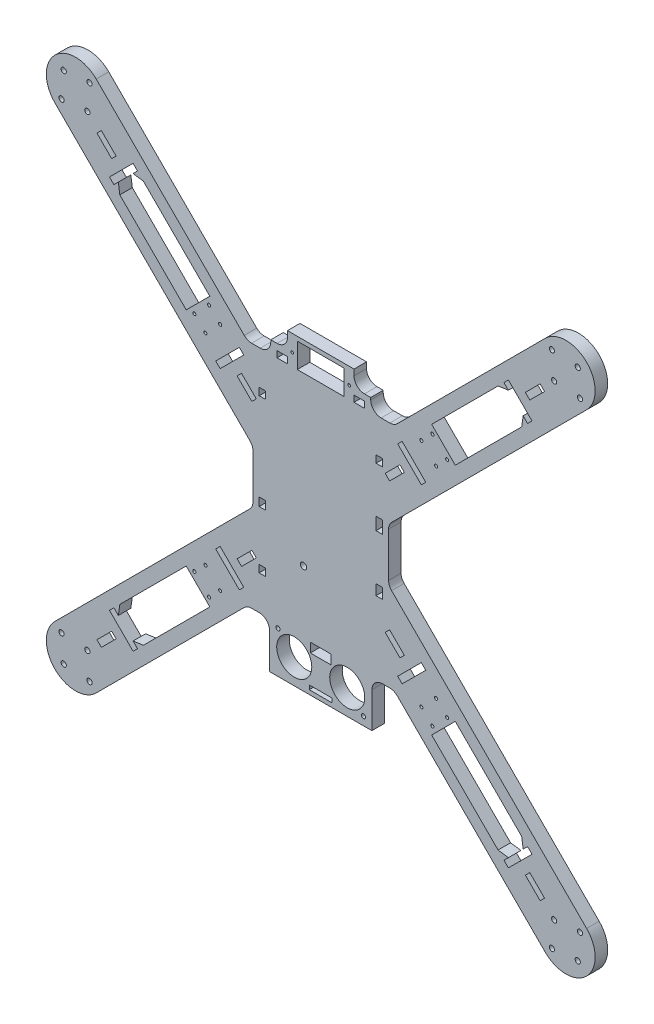
from build123d import *

# Parameters (mm, degrees)
BOSS_EXTRUDE1_DEPTH = 6
SKETCH4_R           = 1.25
CUT_EXTRUDE1_DEPTH  = 7
SKETCH5_R           = 0.65
SKETCH5_W           = 22.5
SKETCH5_H           = 11.8
CUT_EXTRUDE2_DEPTH  = 7
SKETCH6_R           = 1.5
CUT_EXTRUDE3_DEPTH  = 7
SKETCH7_R           = 1
SKETCH7_R_2         = 8.4
SKETCH7_W           = 10
SKETCH7_H           = 4.5
SKETCH7_W_2         = 11
SKETCH7_H_2         = 2
CUT_EXTRUDE4_DEPTH  = 7
CUT_EXTRUDE5_DEPTH  = 7
BOSS_EXTRUDE2_REACH = 195.969
SKETCH9_W           = 6
SKETCH9_H           = 20
BOSS_EXTRUDE3_REACH = 195.969
SKETCH11_W          = 6
SKETCH11_H          = 20
BOSS_EXTRUDE4_REACH = 195.969
SKETCH12_W          = 6
SKETCH12_H          = 20
BOSS_EXTRUDE5_REACH = 195.969
SKETCH13_W          = 6
SKETCH13_H          = 20
SKETCH14_W          = 3
SKETCH14_H          = 6
SKETCH14_H_2        = 3.5
SKETCH14_H_3        = 4
SKETCH14_H_4        = 5
CUT_EXTRUDE6_DEPTH  = 7
SKETCH15_R          = 0.75
CUT_EXTRUDE7_DEPTH  = 7
SKETCH17_W          = 8
SKETCH17_H          = 6
BOSS_EXTRUDE8_DEPTH = 6
SKETCH19_W          = 5
SKETCH19_H          = 3
CUT_EXTRUDE9_DEPTH  = 7
FILLET1_R           = 5


with BuildPart() as part:
    # Sketch1 → Boss-Extrude1 (new body)
    with BuildSketch(Plane.XY):
        with BuildLine():
            Line((35.201010127, 55), (15.95, 55))
            Line((15.95, 55), (15.95, 68.8))
            Line((15.95, 68.8), (-15.95, 68.8))
            Line((-15.95, 68.8), (-15.95, 55))
            Line((-15.95, 55), (-35.201010127, 55))
            Line((-35.201010127, 55), (-107.600505063, 127.399494937))
            ThreePointArc((-107.600505063, 127.399494937), (-127.399494937, 127.399494937), (-127.399494937, 107.600505063))
            Line((-127.399494937, 107.600505063), (-32.5, 12.701010127))
            Line((-32.5, 12.701010127), (-32.5, -12.701010127))
            Line((-32.5, -12.701010127), (-127.399494937, -107.600505063))
            ThreePointArc((-127.399494937, -107.600505063), (-127.399494937, -127.399494937), (-107.600505063, -127.399494937))
            Line((-107.600505063, -127.399494937), (-35.201010127, -55))
            Line((-35.201010127, -55), (-24.5, -55))
            Line((-24.5, -55), (-24.5, -77))
            Line((-24.5, -77), (24.5, -77))
            Line((24.5, -77), (24.5, -55))
            Line((24.5, -55), (35.201010127, -55))
            Line((35.201010127, -55), (107.600505063, -127.399494937))
            ThreePointArc((107.600505063, -127.399494937), (127.399494937, -127.399494937), (127.399494937, -107.600505063))
            Line((127.399494937, -107.600505063), (32.5, -12.701010127))
            Line((32.5, -12.701010127), (32.5, 12.701010127))
            Line((32.5, 12.701010127), (127.399494937, 107.600505063))
            ThreePointArc((127.399494937, 107.600505063), (127.399494937, 127.399494937), (107.600505063, 127.399494937))
            Line((107.600505063, 127.399494937), (35.201010127, 55))
        make_face()
    extrude(amount=-BOSS_EXTRUDE1_DEPTH)

    # Sketch4 → Cut-Extrude1 (cut, through all)
    with BuildSketch(Plane.XY):
        with Locations((-110.782485579, 124.217514421)):
            Circle(SKETCH4_R)
        with Locations((-124.217514421, 110.782485579)):
            Circle(SKETCH4_R)
        with Locations((-123.156854249, 123.156854249)):
            Circle(SKETCH4_R)
        with Locations((-111.843145751, 111.843145751)):
            Circle(SKETCH4_R)
        with Locations((111.843145751, 111.843145751)):
            Circle(SKETCH4_R)
        with Locations((110.782485579, 124.217514421)):
            Circle(SKETCH4_R)
        with Locations((123.156854249, 123.15685425)):
            Circle(SKETCH4_R)
        with Locations((124.217514421, 110.782485579)):
            Circle(SKETCH4_R)
        with Locations((111.843145751, -111.84314575)):
            Circle(SKETCH4_R)
        with Locations((124.217514421, -110.782485579)):
            Circle(SKETCH4_R)
        with Locations((123.15685425, -123.156854249)):
            Circle(SKETCH4_R)
        with Locations((110.782485579, -124.217514421)):
            Circle(SKETCH4_R)
        with Locations((-111.84314575, -111.843145751)):
            Circle(SKETCH4_R)
        with Locations((-110.782485579, -124.217514421)):
            Circle(SKETCH4_R)
        with Locations((-123.156854249, -123.156854249)):
            Circle(SKETCH4_R)
        with Locations((-124.217514421, -110.782485579)):
            Circle(SKETCH4_R)
    extrude(amount=-CUT_EXTRUDE1_DEPTH, mode=Mode.SUBTRACT)

    # Sketch5 → Cut-Extrude2 (cut, through all)
    with BuildSketch(Plane.XY):
        with Locations((-13.65, 60.9)):
            Circle(SKETCH5_R)
        with Locations((13.65, 60.9)):
            Circle(SKETCH5_R)
        with Locations((0, 60.9)):
            Rectangle(SKETCH5_W, SKETCH5_H)
    extrude(amount=-CUT_EXTRUDE2_DEPTH, mode=Mode.SUBTRACT)

    # Sketch6 → Cut-Extrude3 (cut, through all)
    with BuildSketch(Plane.XY):
        with Locations((-8.25, -25)):
            Circle(SKETCH6_R)
    extrude(amount=-CUT_EXTRUDE3_DEPTH, mode=Mode.SUBTRACT)

    # Sketch7 → Cut-Extrude4 (cut, through all)
    with BuildSketch(Plane.XY):
        with Locations((-20.5, -57)):
            Circle(SKETCH7_R)
        with Locations((-12.7, -65)):
            Circle(SKETCH7_R_2)
        with Locations((12.7, -65)):
            Circle(SKETCH7_R_2)
        with Locations((20.5, -73)):
            Circle(SKETCH7_R)
        with Locations((0, -57.25)):
            Rectangle(SKETCH7_W, SKETCH7_H)
        with Locations((0, -74)):
            Rectangle(SKETCH7_W_2, SKETCH7_H_2)
    extrude(amount=-CUT_EXTRUDE4_DEPTH, mode=Mode.SUBTRACT)

    # Sketch8 → Cut-Extrude5 (cut, through all)
    with BuildSketch(Plane.XY):
        Polygon((101.236544033, -89.922835534), (89.922835534, -101.236544033), (87.80151519, -99.115223689), (89.922835534, -96.993903346), (84.973088065, -96.286796564), (41.839574413, -53.153282912), (39.011147288, -50.324855787), (36.889826945, -48.203535444), (48.203535444, -36.889826945), (50.324855787, -39.011147288), (53.153282912, -41.839574413), (96.286796564, -84.973088065), (96.993903346, -89.922835534), (99.115223689, -87.80151519), align=None)
        Polygon((40.07180746, -37.950487117), (37.950487117, -40.07180746), (30.879419305, -33.000739648), (33.000739648, -30.879419305), align=None)
        Polygon((50.324855787, 39.011147288), (48.203535444, 36.889826945), (36.889826945, 48.203535444), (39.011147288, 50.324855787), (41.839574413, 53.153282912), (84.973088065, 96.286796564), (89.922835534, 96.993903346), (87.80151519, 99.115223689), (89.922835534, 101.236544033), (101.236544033, 89.922835534), (99.115223689, 87.80151519), (96.993903346, 89.922835534), (96.286796564, 84.973088065), (53.153282912, 41.839574413), align=None)
        Polygon((100.175883861, -98.054563517), (98.054563517, -100.175883861), (105.125631329, -107.246951673), (107.246951673, -105.125631329), align=None)
        Polygon((-101.236544033, -89.922835534), (-99.115223689, -87.80151519), (-96.993903346, -89.922835534), (-96.286796564, -84.973088065), (-53.153282912, -41.839574413), (-50.324855787, -39.011147288), (-48.203535444, -36.889826945), (-36.889826945, -48.203535444), (-39.011147288, -50.324855787), (-41.839574413, -53.153282912), (-84.973088065, -96.286796564), (-89.922835534, -96.993903346), (-87.80151519, -99.115223689), (-89.922835534, -101.236544033), align=None)
        Polygon((-100.175883861, -98.054563517), (-107.246951673, -105.125631329), (-105.125631329, -107.246951673), (-98.054563517, -100.175883861), align=None)
        Polygon((-37.950487117, -40.07180746), (-40.07180746, -37.950487117), (-33.000739648, -30.879419305), (-30.879419305, -33.000739648), align=None)
        Polygon((-89.922835534, 101.236544033), (-87.80151519, 99.115223689), (-89.922835534, 96.993903346), (-84.973088065, 96.286796564), (-41.839574413, 53.153282912), (-39.011147288, 50.324855787), (-36.889826945, 48.203535444), (-48.203535444, 36.889826945), (-50.324855787, 39.011147288), (-53.153282912, 41.839574413), (-96.286796564, 84.973088065), (-96.993903346, 89.922835534), (-99.115223689, 87.80151519), (-101.236544033, 89.922835534), align=None)
        Polygon((-98.054563517, 100.175883861), (-105.125631329, 107.246951673), (-107.246951673, 105.125631329), (-100.175883861, 98.054563517), align=None)
        Polygon((-40.07180746, 37.950487117), (-37.950487117, 40.07180746), (-30.879419305, 33.000739648), (-33.000739648, 30.879419305), align=None)
        Polygon((100.175883861, 98.054563517), (107.246951673, 105.125631329), (105.125631329, 107.246951673), (98.054563517, 100.175883861), align=None)
        Polygon((37.950487117, 40.07180746), (40.07180746, 37.950487117), (33.000739648, 30.879419305), (30.879419305, 33.000739648), align=None)
    extrude(amount=-CUT_EXTRUDE5_DEPTH, mode=Mode.SUBTRACT)

    # Sketch9 → Boss-Extrude2 (add, up to next)
    with BuildSketch(Plane(origin=(-5.656854249, 5.656854249, 0), x_dir=(0, 0, -1), z_dir=(0.707106781, -0.707106781, 0)), mode=Mode.PRIVATE) as boss_extrude2_sk1:
        with Locations((3, 73.170093579)):
            Rectangle(SKETCH9_W, SKETCH9_H)
    boss_extrude2_tool1 = extrude(boss_extrude2_sk1.sketch, amount=BOSS_EXTRUDE2_REACH, mode=Mode.PRIVATE) - part.part
    add(boss_extrude2_tool1.solids().sort_by_distance((46.082215, 57.395924, -3))[0])

    # Sketch11 → Boss-Extrude3 (add, up to next)
    with BuildSketch(Plane(origin=(5.656854249, 5.656854249, 0), x_dir=(0, 0, 1), z_dir=(-0.707106781, -0.707106781, 0)), mode=Mode.PRIVATE) as boss_extrude3_sk1:
        with Locations((-3, -73.170093579)):
            Rectangle(SKETCH11_W, SKETCH11_H)
    boss_extrude3_tool1 = extrude(boss_extrude3_sk1.sketch, amount=BOSS_EXTRUDE3_REACH, mode=Mode.PRIVATE) - part.part
    add(boss_extrude3_tool1.solids().sort_by_distance((57.395924, -46.082215, -3))[0])

    # Sketch12 → Boss-Extrude4 (add, up to next)
    with BuildSketch(Plane(origin=(5.656854249, -5.656854249, 0), x_dir=(0, 0, 1), z_dir=(-0.707106781, 0.707106781, 0)), mode=Mode.PRIVATE) as boss_extrude4_sk1:
        with Locations((-3, -73.170093579)):
            Rectangle(SKETCH12_W, SKETCH12_H)
    boss_extrude4_tool1 = extrude(boss_extrude4_sk1.sketch, amount=BOSS_EXTRUDE4_REACH, mode=Mode.PRIVATE) - part.part
    add(boss_extrude4_tool1.solids().sort_by_distance((-46.082215, -57.395924, -3))[0])

    # Sketch13 → Boss-Extrude5 (add, up to next)
    with BuildSketch(Plane(origin=(5.656854249, 5.656854249, 0), x_dir=(0, 0, 1), z_dir=(-0.707106781, -0.707106781, 0)), mode=Mode.PRIVATE) as boss_extrude5_sk1:
        with Locations((-3, 73.170093579)):
            Rectangle(SKETCH13_W, SKETCH13_H)
    boss_extrude5_tool1 = extrude(boss_extrude5_sk1.sketch, amount=BOSS_EXTRUDE5_REACH, mode=Mode.PRIVATE) - part.part
    add(boss_extrude5_tool1.solids().sort_by_distance((-46.082215, 57.395924, -3))[0])

    # Sketch14 → Cut-Extrude6 (cut, through all)
    with BuildSketch(Plane(origin=(0, 0, -6), x_dir=(-1, 0, 0), z_dir=(0, 0, -1))):
        with Locations((-28, 10)):
            Rectangle(SKETCH14_W, SKETCH14_H)
        with Locations((28, -36.75)):
            Rectangle(SKETCH14_W, SKETCH14_H_2)
        with Locations((28, -9)):
            Rectangle(SKETCH14_W, SKETCH14_H_3)
        with Locations((28, 36.75)):
            Rectangle(SKETCH14_W, SKETCH14_H_2)
        with Locations((-28, -17.5)):
            Rectangle(SKETCH14_W, SKETCH14_H_4)
        with Locations((-28, 36.75)):
            Rectangle(SKETCH14_W, SKETCH14_H_2)
    extrude(amount=-CUT_EXTRUDE6_DEPTH, mode=Mode.SUBTRACT)

    # Sketch15 → Cut-Extrude7 (cut, through all)
    with BuildSketch(Plane(origin=(0, 0, -6), x_dir=(-1, 0, 0), z_dir=(0, 0, -1))):
        with Locations((-60.577904114, -53.506836303)):
            Circle(SKETCH15_R)
        with Locations((-55.274603256, -48.203535444)):
            Circle(SKETCH15_R)
        with Locations((-48.203535444, -55.274603256)):
            Circle(SKETCH15_R)
        with Locations((-53.506836303, -60.577904114)):
            Circle(SKETCH15_R)
        with Locations((-53.506836303, 60.577904114)):
            Circle(SKETCH15_R)
        with Locations((-48.203535444, 55.274603256)):
            Circle(SKETCH15_R)
        with Locations((-60.577904114, 53.506836303)):
            Circle(SKETCH15_R)
        with Locations((-55.274603256, 48.203535444)):
            Circle(SKETCH15_R)
        with Locations((60.577904114, 53.506836303)):
            Circle(SKETCH15_R)
        with Locations((55.274603256, 48.203535444)):
            Circle(SKETCH15_R)
        with Locations((53.506836303, 60.577904114)):
            Circle(SKETCH15_R)
        with Locations((48.203535444, 55.274603256)):
            Circle(SKETCH15_R)
        with Locations((53.506836303, -60.577904114)):
            Circle(SKETCH15_R)
        with Locations((48.203535444, -55.274603256)):
            Circle(SKETCH15_R)
        with Locations((60.577904114, -53.506836303)):
            Circle(SKETCH15_R)
        with Locations((55.274603256, -48.203535444)):
            Circle(SKETCH15_R)
    extrude(amount=-CUT_EXTRUDE7_DEPTH, mode=Mode.SUBTRACT)

    # Sketch17 → Boss-Extrude8 (add)
    with BuildSketch(Plane(origin=(0, 0, -6), x_dir=(-1, 0, 0), z_dir=(0, 0, -1))):
        with Locations((19.95, 58)):
            Rectangle(SKETCH17_W, SKETCH17_H)
        with Locations((-19.95, 58)):
            Rectangle(SKETCH17_W, SKETCH17_H)
    extrude(amount=-BOSS_EXTRUDE8_DEPTH)

    # Sketch19 → Cut-Extrude9 (cut, through all)
    with BuildSketch(Plane(origin=(0, 0, -6), x_dir=(-1, 0, 0), z_dir=(0, 0, -1))):
        with Locations((18.45, 56.5)):
            Rectangle(SKETCH19_W, SKETCH19_H)
        with Locations((-18.45, 56.5)):
            Rectangle(SKETCH19_W, SKETCH19_H)
    extrude(amount=-CUT_EXTRUDE9_DEPTH, mode=Mode.SUBTRACT)

    # Fillet1
    fillet1_edges = [part.edges().sort_by_distance(p)[0] for p in [
        (-35.201010127, -55, -3),
        (-32.5, -12.701010127, -3),
        (-32.5, 12.701010127, -3),
        (-35.201010127, 55, -3),
        (35.201010127, 55, -3),
        (32.5, 12.701010127, -3),
        (32.5, -12.701010127, -3),
        (35.201010127, -55, -3),
        (24.5, -55, -3),
        (-24.5, -55, -3),
        (-23.95, 55, -3),
        (-15.95, 61, -3),
        (23.95, 55, -3),
        (15.95, 61, -3),
    ]]
    fillet(fillet1_edges, radius=FILLET1_R)


solid = part.part
